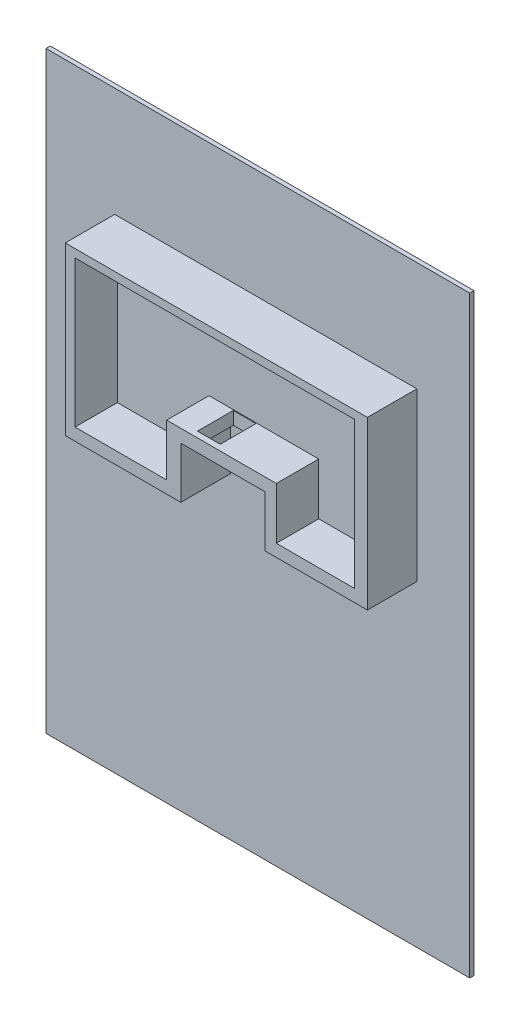
from build123d import *

# Parameters (mm, degrees)
IZIM1_W                     = 30000
IZIM1_H                     = 42000
Y_KSEKLIK_EKSTR_ZYON1_DEPTH = 300
Y_KSEKLIK_EKSTR_ZYON2_DEPTH = 800
Y_KSEKLIK_EKSTR_ZYON4_DEPTH = 3000
IZIM4_W                     = 1609.784824537
IZIM4_H                     = 2534.03541531
KES_EKSTR_ZYON1_DEPTH       = 2062


with BuildPart() as part:
    # Çizim1 → Yükseklik-Ekstrüzyon1 (new body)
    with BuildSketch(Plane.XY):
        with Locations((1193.199328836, -15982.847341338)):
            Rectangle(IZIM1_W, IZIM1_H)
    extrude(amount=Y_KSEKLIK_EKSTR_ZYON1_DEPTH)

    # Çizim2 → Yükseklik-Ekstrüzyon2 (add)
    with BuildSketch(Plane.XY):
        Polygon((-8945.803973005, -14541.06246814), (-760.186628399, -14541.06246814), (-760.186628399, -10913.345690417), (5192.989622223, -10913.345690417), (5192.989622223, -14541.06246814), (12448.423177669, -14541.06246814), (12448.423177669, -2727.728345812), (-8945.803973005, -2727.728345812), align=None)
    extrude(amount=Y_KSEKLIK_EKSTR_ZYON2_DEPTH)

    # Çizim3 → Yükseklik-Ekstrüzyon4 (add)
    with BuildSketch(Plane.XY.offset(800)):
        Polygon((-8945.803973005, -2727.728345812), (12448.423177669, -2727.728345812), (12448.423177669, -14541.06246814), (5192.989622223, -14541.06246814), (5192.989622223, -10913.345690417), (-760.186628399, -10913.345690417), (-760.186628399, -14541.06246814), (-8945.803973005, -14541.06246814), align=None)
        Polygon((-8253.930968423, -3301.785557638), (11531.521366561, -3301.785557638), (11531.521366561, -13673.192023557), (6000.104584738, -13673.192023557), (6000.104584738, -10003.309735616), (-1765.153589745, -10003.309735616), (-1765.153589745, -13673.192023557), (-8253.930968423, -13673.192023557), align=None, mode=Mode.SUBTRACT)
    extrude(amount=Y_KSEKLIK_EKSTR_ZYON4_DEPTH)

    # Çizim4 → Kes-Ekstrüzyon1 (cut)
    with BuildSketch(Plane.XZ.offset(10913.345690417)):
        with Locations((804.892412269, 2115.198946394)):
            Rectangle(IZIM4_W, IZIM4_H)
    extrude(amount=-KES_EKSTR_ZYON1_DEPTH, mode=Mode.SUBTRACT)


solid = part.part
